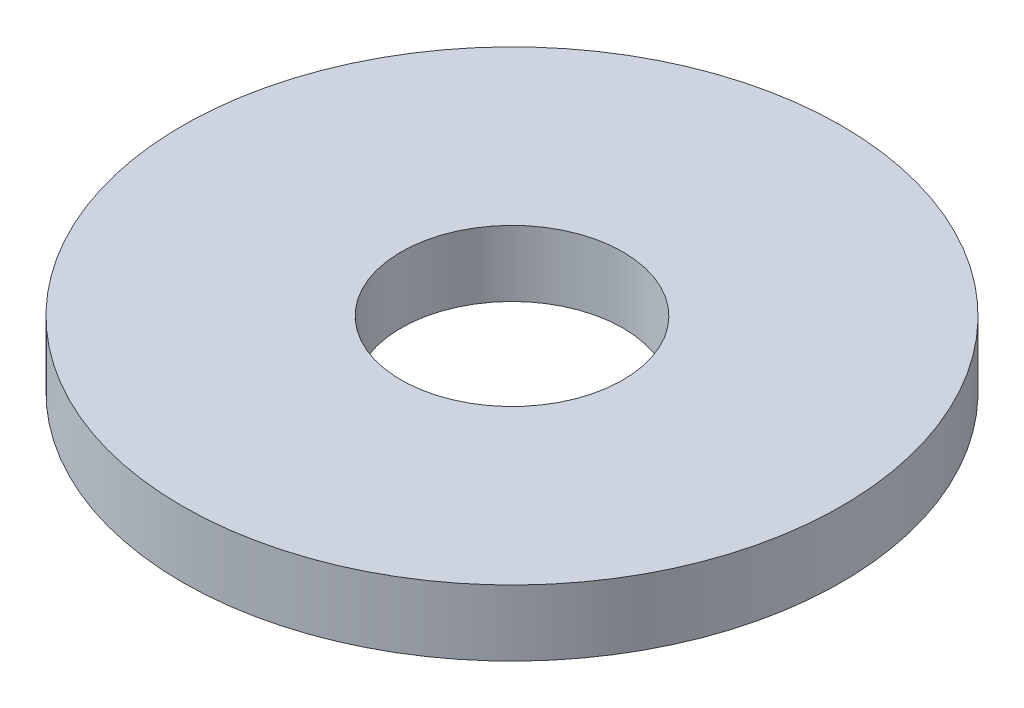
from build123d import *

# Parameters (mm, degrees)
SKETCH1_R           = 1.5
BOSS_EXTRUDE1_DEPTH = 0.3
SKETCH2_R           = 0.505
CUT_EXTRUDE1_DEPTH  = 1.3


with BuildPart() as part:
    # Sketch1 → Boss-Extrude1 (new body)
    with BuildSketch(Plane(origin=(0, 0, 0), x_dir=(1, 0, 0), z_dir=(0, 1, 0))):
        Circle(SKETCH1_R)
    extrude(amount=BOSS_EXTRUDE1_DEPTH)

    # Sketch2 → Cut-Extrude1 (cut, through all)
    with BuildSketch(Plane.XZ):
        Circle(SKETCH2_R)
    extrude(amount=-CUT_EXTRUDE1_DEPTH, mode=Mode.SUBTRACT)


solid = part.part
